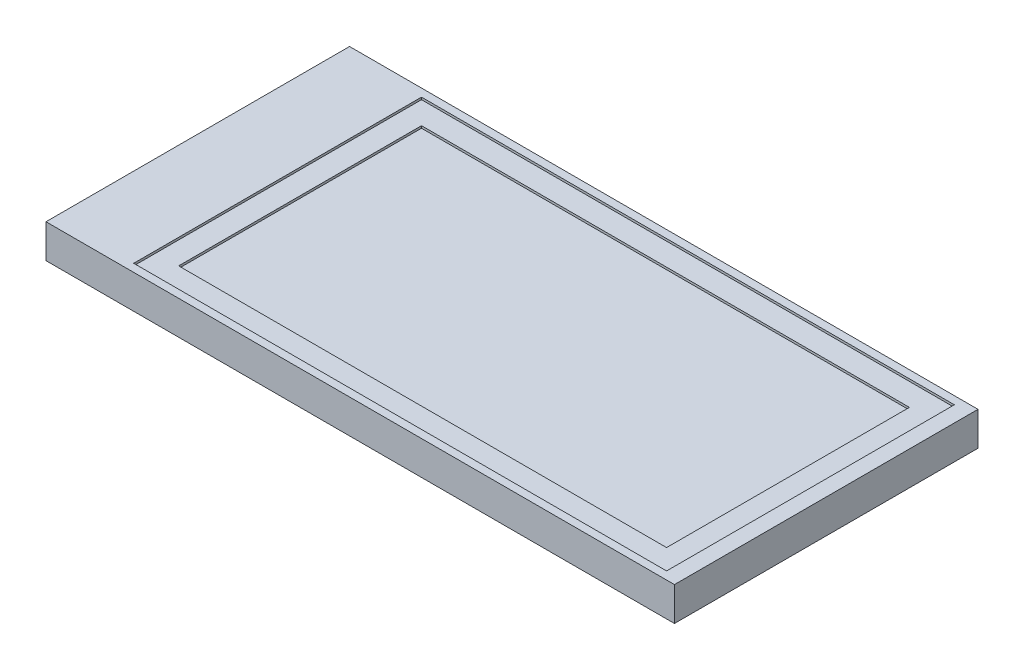
from build123d import *

# Parameters (mm, degrees)
SKETCH1_W           = 27.95
SKETCH1_H           = 13.5
BOSS_EXTRUDE1_DEPTH = 1.5
SKETCH2_W           = 21.7
SKETCH2_H           = 10.8
CUT_EXTRUDE1_DEPTH  = 0.2
SKETCH3_W           = 23.7
SKETCH3_H           = 12.8
CUT_EXTRUDE2_DEPTH  = 0.1


with BuildPart() as part:
    # Sketch1 → Boss-Extrude1 (new body)
    with BuildSketch(Plane(origin=(0, 0, 0), x_dir=(1, 0, 0), z_dir=(0, 1, 0))):
        with Locations((-1.425, 0)):
            Rectangle(SKETCH1_W, SKETCH1_H)
    extrude(amount=BOSS_EXTRUDE1_DEPTH)

    # Sketch2 → Cut-Extrude1 (cut)
    with BuildSketch(Plane(origin=(0, 1.5, 0), x_dir=(1, 0, 0), z_dir=(0, 1, 0))):
        Rectangle(SKETCH2_W, SKETCH2_H)
    extrude(amount=-CUT_EXTRUDE1_DEPTH, mode=Mode.SUBTRACT)

    # Sketch3 → Cut-Extrude2 (cut)
    with BuildSketch(Plane(origin=(0, 1.5, 0), x_dir=(1, 0, 0), z_dir=(0, 1, 0))):
        Rectangle(SKETCH3_W, SKETCH3_H)
    extrude(amount=-CUT_EXTRUDE2_DEPTH, mode=Mode.SUBTRACT)


solid = part.part
